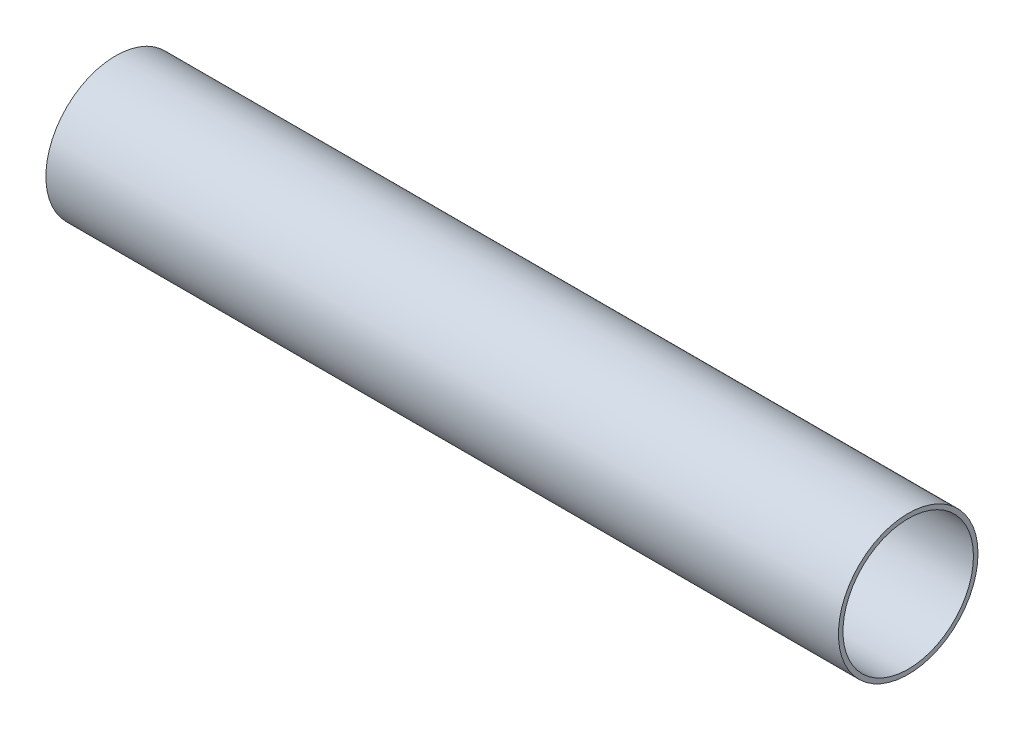
from build123d import *

# Parameters (mm, degrees)
SKETCH1_R           = 45.847
SKETCH1_R_2         = 42.8625
BOSS_EXTRUDE1_DEPTH = 520.7


with BuildPart() as part:
    # Sketch1 → Boss-Extrude1 (new body)
    with BuildSketch(Plane(origin=(0, 0, 0), x_dir=(0, 0, -1), z_dir=(1, 0, 0))):
        Circle(SKETCH1_R)
        Circle(SKETCH1_R_2, mode=Mode.SUBTRACT)
    extrude(amount=BOSS_EXTRUDE1_DEPTH)


solid = part.part
